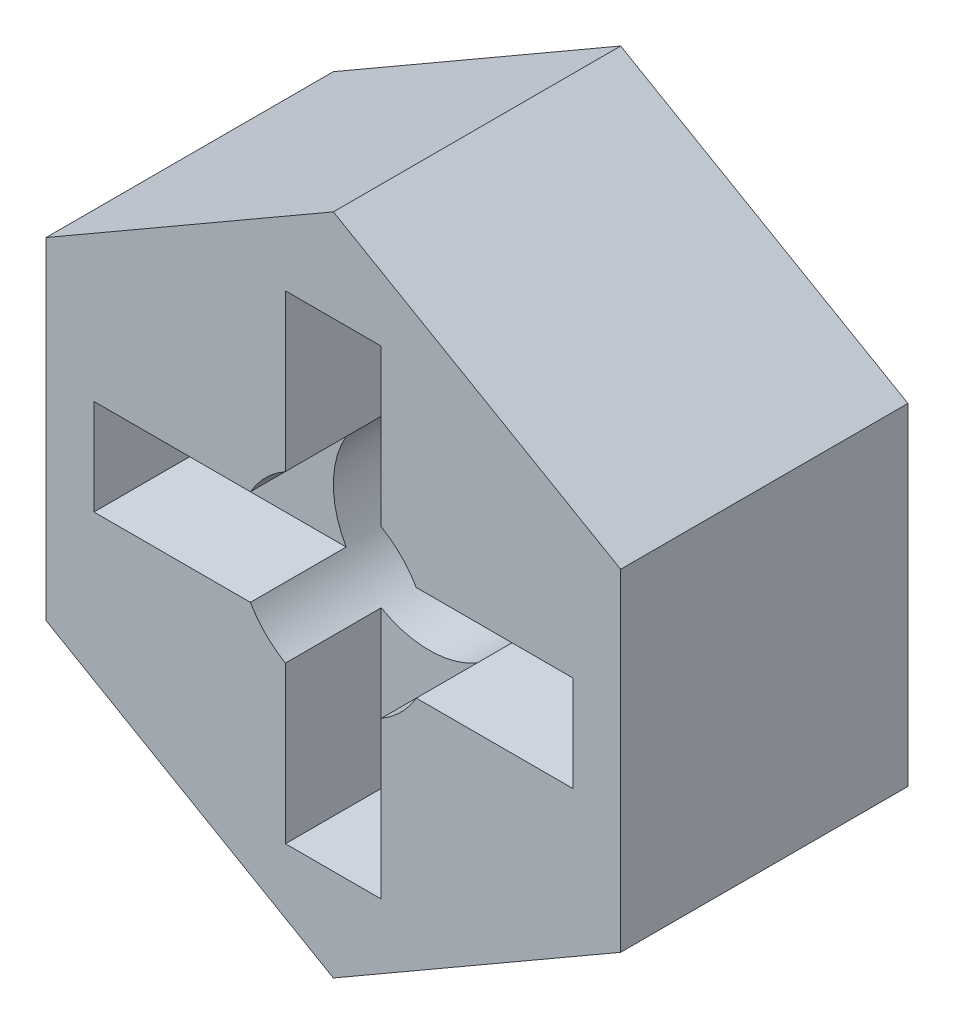
from build123d import *

# Parameters (mm, degrees)
ESQUISSE1_R             = 2
BASE_EXTRUSION_DEPTH    = 6
ESQUISSE2_W             = 4
ESQUISSE2_H             = 2
ESQUISSE2_W_2           = 2
ESQUISSE2_H_2           = 4
ENL_V_MAT_EXTRU_1_DEPTH = 2
ESQUISSE3_R             = 5
ESQUISSE3_R_2           = 4
ENL_V_MAT_EXTRU_2_DEPTH = 2


with BuildPart() as part:
    # Esquisse1 → Base-Extrusion (new body)
    with BuildSketch(Plane.XY):
        Polygon((0, 6.92820323), (-6, 3.464101615), (-6, -3.464101615), (0, -6.92820323), (6, -3.464101615), (6, 3.464101615), align=None)
        Circle(ESQUISSE1_R, mode=Mode.SUBTRACT)
    extrude(amount=BASE_EXTRUSION_DEPTH)

    # Esquisse2 → Enlèv. mat.-Extru.1 (cut)
    with BuildSketch(Plane.XY.offset(6)):
        Polygon((1, 1), (1, 5), (-1, 5), (-1, 1), (-1, -1), (1, -1), align=None)
        with Locations((3, 0)):
            Rectangle(ESQUISSE2_W, ESQUISSE2_H)
        with Locations((-3, 0)):
            Rectangle(ESQUISSE2_W, ESQUISSE2_H)
        with Locations((0, -3)):
            Rectangle(ESQUISSE2_W_2, ESQUISSE2_H_2)
    extrude(amount=-ENL_V_MAT_EXTRU_1_DEPTH, mode=Mode.SUBTRACT)

    # Esquisse3 → Enlèv. mat.-Extru.2 (cut)
    with BuildSketch(Plane(origin=(0, 0, 0), x_dir=(-1, 0, 0), z_dir=(0, 0, -1))):
        Circle(ESQUISSE3_R)
        Circle(ESQUISSE3_R_2, mode=Mode.SUBTRACT)
    extrude(amount=-ENL_V_MAT_EXTRU_2_DEPTH, mode=Mode.SUBTRACT)


solid = part.part
